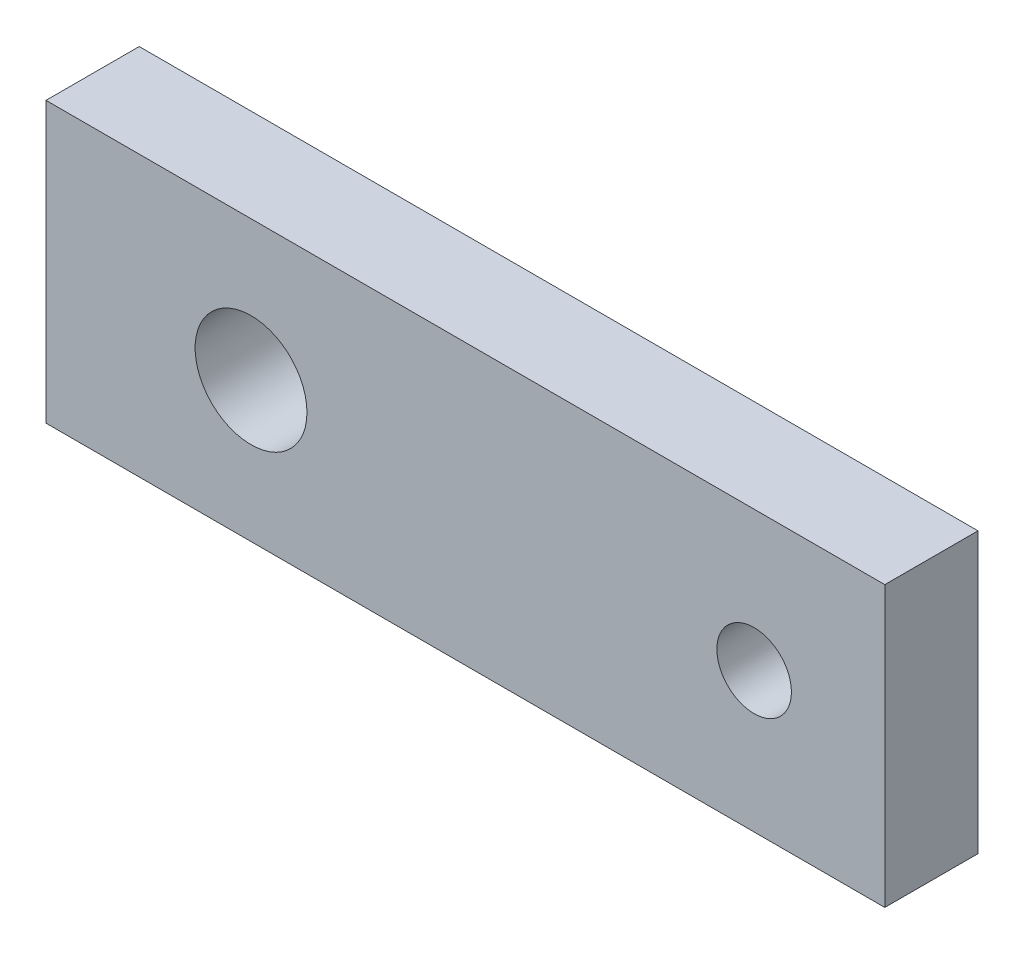
from build123d import *

# Parameters (mm, degrees)
SKETCH1_W           = 90
SKETCH1_H           = 30
SKETCH1_R           = 6
SKETCH1_R_2         = 4
BOSS_EXTRUDE1_DEPTH = 10


with BuildPart() as part:
    # Sketch1 → Boss-Extrude1 (new body)
    with BuildSketch(Plane.XY):
        Rectangle(SKETCH1_W, SKETCH1_H)
        with Locations((-23, 0)):
            Circle(SKETCH1_R, mode=Mode.SUBTRACT)
        with Locations((30.98, 0)):
            Circle(SKETCH1_R_2, mode=Mode.SUBTRACT)
    extrude(amount=BOSS_EXTRUDE1_DEPTH)


solid = part.part
